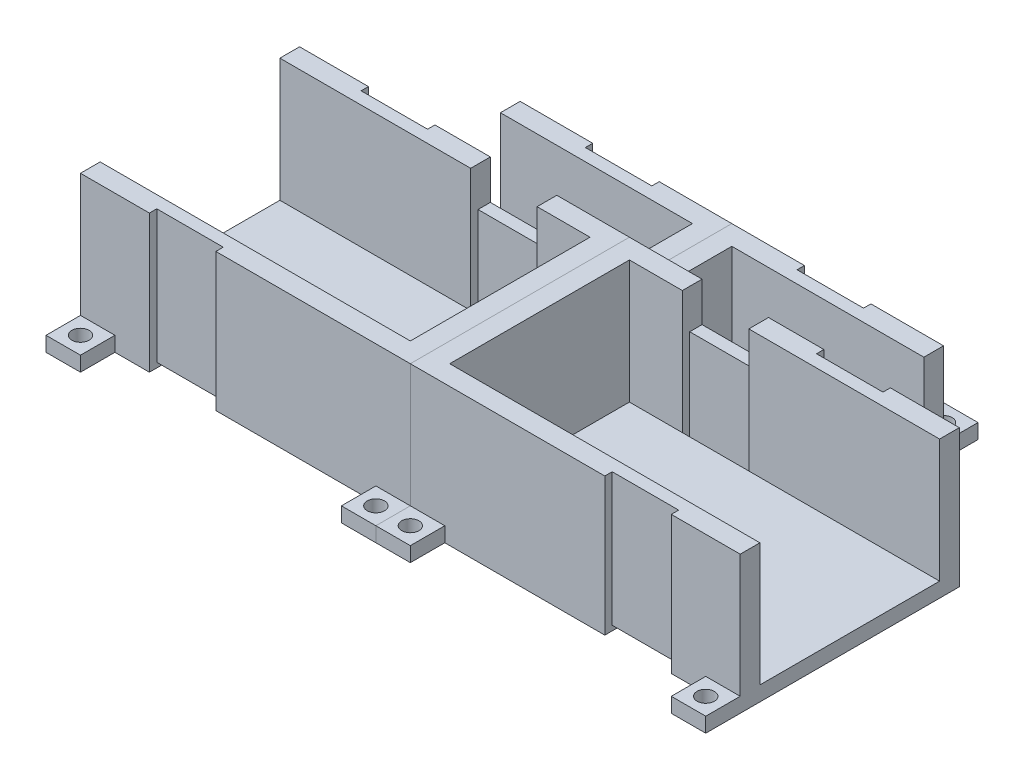
from build123d import *

# Parameters (mm, degrees)
SKETCH1_R               = 1.75
BOSS_EXTRUDE1_DEPTH     = 3
BOSS_EXTRUDE2_START     = 3
SKETCH1_5_W             = 13.5
SKETCH1_5_H             = 2.5
BOSS_EXTRUDE2_DEPTH     = 25
SKETCH1_6_W             = 13.5
SKETCH1_6_H             = 2.5
BOSS_EXTRUDE3_DEPTH     = 20
SKETCH1_7_W             = 13.5
SKETCH1_7_H             = 1.5
CUT_EXTRUDE1_DEPTH      = 29
CUT_EXTRUDE1_DEPTH_BACK = 1
SKETCH1_8_W             = 13.5
SKETCH1_8_H             = 16.8
SKETCH1_8_H_2           = 2.5
SKETCH1_8_H_3           = 36.5
CUT_EXTRUDE2_DEPTH      = 1


with BuildPart() as part:
    # Sketch1 → Boss-Extrude1 (new body)
    with BuildSketch(Plane(origin=(0, 0, 0), x_dir=(1, 0, 0), z_dir=(0, 1, 0))):
        Polygon((-33.5, 11.85), (-33.5, -39.65), (-26.5, -39.65), (-26.5, -32.65), (26.5, -32.65), (26.5, -39.65), (33.5, -39.65), (33.5, 32.65), (-2.5, 32.65), (-2.5, 39.65), (-9.5, 39.65), (-9.5, 11.85), align=None)
        with Locations((-30, -36.15)):
            Circle(SKETCH1_R, mode=Mode.SUBTRACT)
        with Locations((30, -36.15)):
            Circle(SKETCH1_R, mode=Mode.SUBTRACT)
        with Locations((-6, 36.15)):
            Circle(SKETCH1_R, mode=Mode.SUBTRACT)
    extrude(amount=BOSS_EXTRUDE1_DEPTH)

    # Sketch1_5 → Boss-Extrude2 (add)
    with BuildSketch(Plane(origin=(0, 0, 0), x_dir=(1, 0, 0), z_dir=(0, 1, 0)).offset(BOSS_EXTRUDE2_START)):
        Polygon((-19.5, -31.15), (-19.5, -28.65), (-33.5, -28.65), (-33.5, -32.65), (-26.5, -32.65), (-19.5, -32.65), align=None)
        with Locations((-12.75, -29.9)):
            Rectangle(SKETCH1_5_W, SKETCH1_5_H)
        Polygon((18.75, 9.35), (18.75, 7.85), (29.5, 7.85), (29.5, -28.65), (-6, -28.65), (-6, -31.15), (-6, -32.65), (26.5, -32.65), (33.5, -32.65), (33.5, 11.85), (29.5, 11.85), (18.75, 11.85), align=None)
        Polygon((-6, 7.85), (5.25, 7.85), (5.25, 9.35), (5.25, 11.85), (-6, 11.85), (-6, 10.35), align=None)
        with Locations((-12.75, 9.1)):
            Rectangle(SKETCH1_5_W, SKETCH1_5_H)
        Polygon((-33.5, 7.85), (-19.5, 7.85), (-19.5, 10.35), (-19.5, 11.85), (-33.5, 11.85), align=None)
    extrude(amount=BOSS_EXTRUDE2_DEPTH)

    # Sketch1_6 → Boss-Extrude3 (add)
    with BuildSketch(Plane(origin=(0, 0, 0), x_dir=(1, 0, 0), z_dir=(0, 1, 0))):
        Polygon((29.5, 28.65), (29.5, 11.85), (33.5, 11.85), (33.5, 32.65), (18.75, 32.65), (18.75, 31.15), (18.75, 28.65), align=None)
        Polygon((-9.5, 28.65), (5.25, 28.65), (5.25, 31.15), (5.25, 32.65), (-2.5, 32.65), (-9.5, 32.65), align=None)
        with Locations((12, 29.9)):
            Rectangle(SKETCH1_6_W, SKETCH1_6_H)
        with Locations((12, 10.6)):
            Rectangle(SKETCH1_6_W, SKETCH1_6_H)
    extrude(amount=BOSS_EXTRUDE3_DEPTH)

    # Sketch1_7 → Cut-Extrude1 (cut, two sides)
    with BuildSketch(Plane(origin=(0, 0, 0), x_dir=(1, 0, 0), z_dir=(0, 1, 0))) as cut_extrude1_sk:
        with Locations((12, 31.9)):
            Rectangle(SKETCH1_7_W, SKETCH1_7_H)
        with Locations((12, 8.6)):
            Rectangle(SKETCH1_7_W, SKETCH1_7_H)
        Polygon((-19.5, 10.35), (-6, 10.35), (-6, 11.85), (-9.5, 11.85), (-19.5, 11.85), align=None)
        with Locations((-12.75, -31.9)):
            Rectangle(SKETCH1_7_W, SKETCH1_7_H)
    extrude(amount=CUT_EXTRUDE1_DEPTH, mode=Mode.SUBTRACT)
    extrude(cut_extrude1_sk.sketch, amount=-CUT_EXTRUDE1_DEPTH_BACK, mode=Mode.SUBTRACT)

    # Sketch1_8 → Cut-Extrude2 (cut)
    with BuildSketch(Plane(origin=(0, 0, 0), x_dir=(1, 0, 0), z_dir=(0, 1, 0))):
        with Locations((12, 20.25)):
            Rectangle(SKETCH1_8_W, SKETCH1_8_H)
        with Locations((12, 29.9)):
            Rectangle(SKETCH1_8_W, SKETCH1_8_H_2)
        with Locations((12, 10.6)):
            Rectangle(SKETCH1_8_W, SKETCH1_8_H_2)
        with Locations((-12.75, -10.4)):
            Rectangle(SKETCH1_8_W, SKETCH1_8_H_3)
        with Locations((-12.75, 9.1)):
            Rectangle(SKETCH1_8_W, SKETCH1_8_H_2)
        with Locations((-12.75, -29.9)):
            Rectangle(SKETCH1_8_W, SKETCH1_8_H_2)
    extrude(amount=CUT_EXTRUDE2_DEPTH, mode=Mode.SUBTRACT)


with BuildPart() as body_2:
    # Mirror1: mirrored copy
    add(part.part.mirror(Plane(origin=(33.5, 3, 0), x_dir=(0, 0, 1), z_dir=(-1, 0, 0))))


solid = Compound([part.part, body_2.part])
